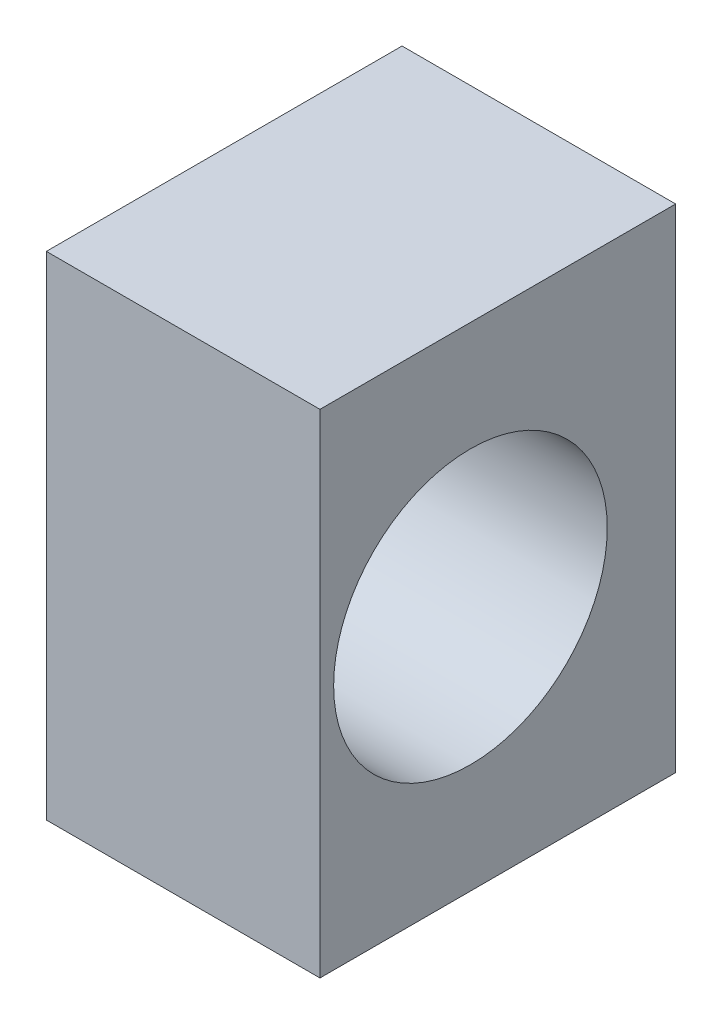
from build123d import *

# Parameters (mm, degrees)
ESQUISSE1_W             = 13
ESQUISSE1_H             = 18
EXTRUSION1_DEPTH        = 10
ESQUISSE2_R             = 5
ENL_V_MAT_EXTRU_1_DEPTH = 11


with BuildPart() as part:
    # Esquisse1 → Extrusion1 (new body)
    with BuildSketch(Plane(origin=(0, 0, 0), x_dir=(0, 0, -1), z_dir=(1, 0, 0))):
        with Locations((6.5, 9)):
            Rectangle(ESQUISSE1_W, ESQUISSE1_H)
    extrude(amount=EXTRUSION1_DEPTH)

    # Esquisse2 → Enlèv. mat.-Extru.1 (cut, through all)
    with BuildSketch(Plane.ZY):
        with Locations((-5.5, 9)):
            Circle(ESQUISSE2_R)
    extrude(amount=-ENL_V_MAT_EXTRU_1_DEPTH, mode=Mode.SUBTRACT)


solid = part.part
